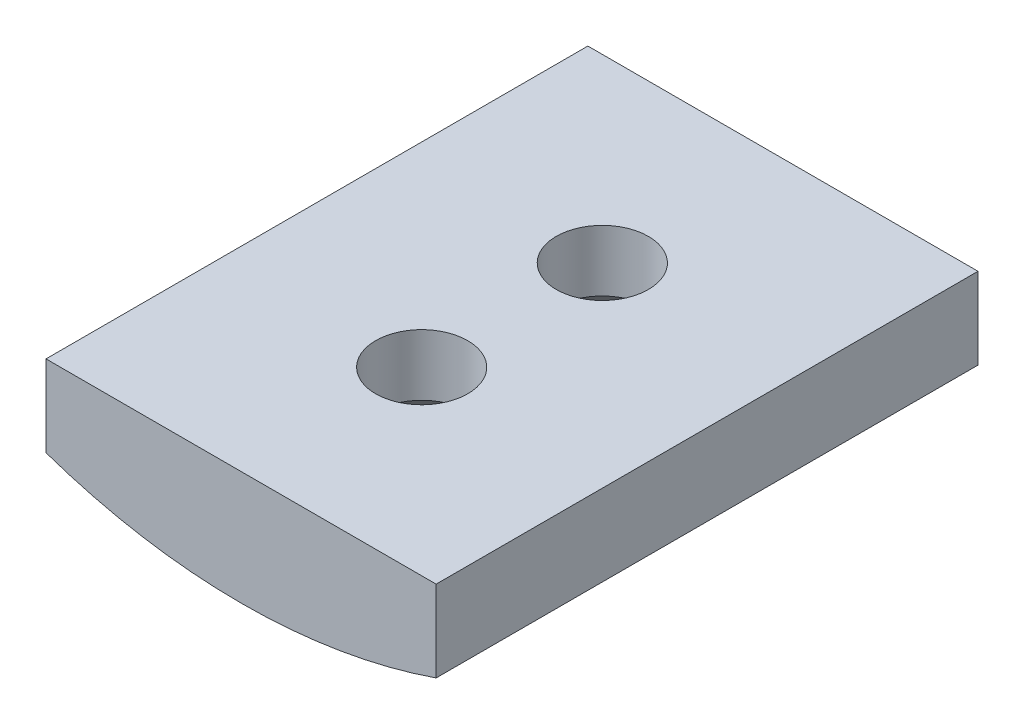
from build123d import *

# Parameters (mm, degrees)
ESTRUSIONE_ESTRUSIONE1_DEPTH           = 20
SCHIZZO2_R                             = 3.15
TAGLIO_ESTRUSIONE1_DEPTH               = 0.5
FORO_SVASATO_PER_VITE_M3_1_D           = 3.4
FORO_SVASATO_PER_VITE_M3_1_CSINK_D     = 6.3
FORO_SVASATO_PER_VITE_M3_1_CSINK_ANGLE = 90


with BuildPart() as part:
    # Schizzo1 → Estrusione-Estrusione1 (new body)
    with BuildSketch(Plane.XY):
        with BuildLine():
            Line((7.2, -12.4), (-7.2, -12.4))
            Line((-7.2, -12.4), (-7.2, -15.4))
            ThreePointArc((-7.2, -15.4), (0, -16.607910427), (7.2, -15.4))
            Line((7.2, -15.4), (7.2, -12.4))
        make_face()
    extrude(amount=-ESTRUSIONE_ESTRUSIONE1_DEPTH)

    # Schizzo2 → Taglio-Estrusione1 (cut)
    with BuildSketch(Plane(origin=(0, -16.607910427, 0), x_dir=(-1, 0, 0), z_dir=(0, -1, 0))):
        with Locations((0, 13.333333333)):
            Circle(SCHIZZO2_R)
        with Locations((0, 6.666666667)):
            Circle(SCHIZZO2_R)
    extrude(amount=-TAGLIO_ESTRUSIONE1_DEPTH, mode=Mode.SUBTRACT)

    # Foro svasato per Vite M3-1 (through all)
    with Locations(Plane(origin=(0, -16.107910427, -6.666666667), x_dir=(-1, 0, 0), z_dir=(0, -1, 0))):
        with Locations((0, 0), (0, 6.666666666)):
            CounterSinkHole(FORO_SVASATO_PER_VITE_M3_1_D / 2, FORO_SVASATO_PER_VITE_M3_1_CSINK_D / 2, counter_sink_angle=FORO_SVASATO_PER_VITE_M3_1_CSINK_ANGLE)


solid = part.part
